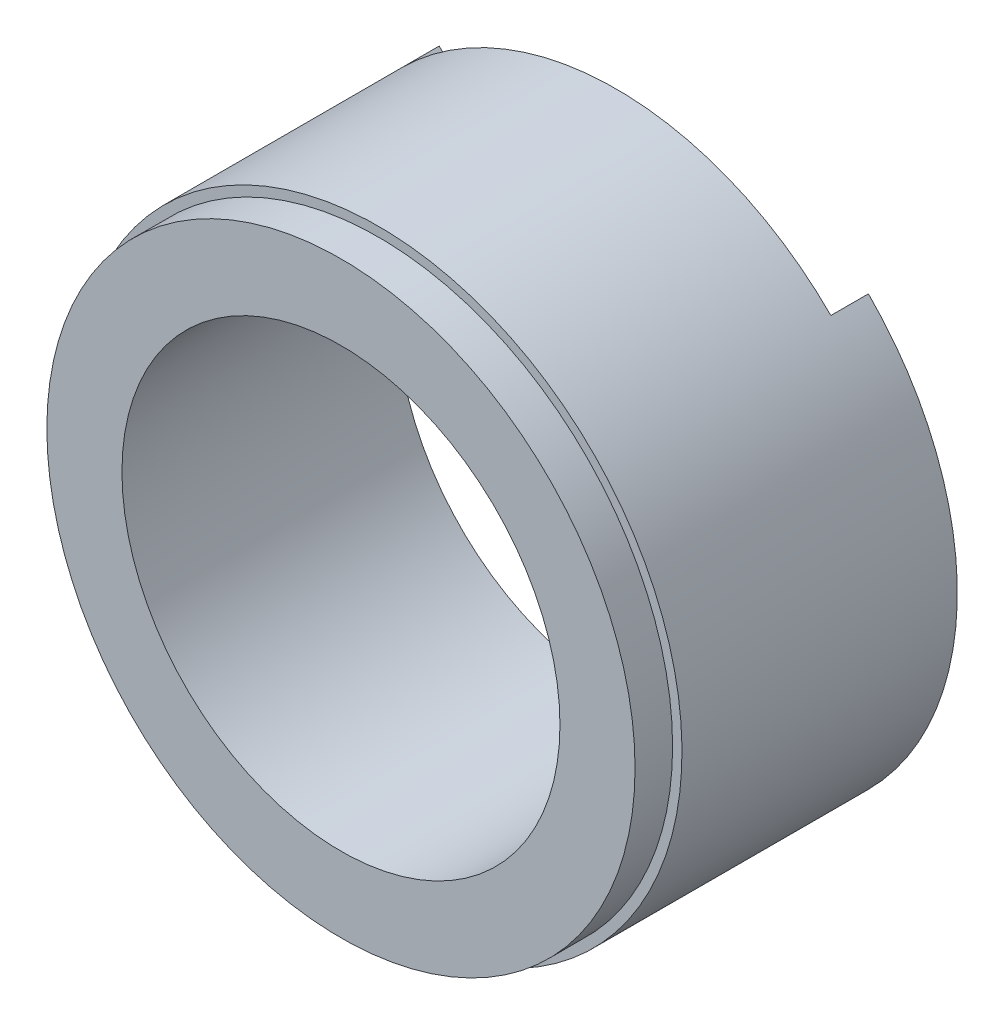
from build123d import *

# Parameters (mm, degrees)
ESQUISSE1_R             = 48.5
BOSS_EXTRU_1_DEPTH      = 44
ESQUISSE2_R             = 48.5
ESQUISSE2_R_2           = 47
ENL_V_MAT_EXTRU_1_DEPTH = 6
ESQUISSE3_R             = 35
ENL_V_MAT_EXTRU_2_DEPTH = 45
ESQUISSE5_R             = 45.5
ESQUISSE5_R_2           = 36.5
ENL_V_MAT_EXTRU_3_DEPTH = 42
ESQUISSE6_W             = 20
ESQUISSE6_H             = 4.166829754
ENL_V_MAT_EXTRU_5_DEPTH = 42
BOSS_EXTRU_2_DEPTH      = 6


with BuildPart() as part:
    # Esquisse1 → Boss.-Extru.1 (new body)
    with BuildSketch(Plane.XY):
        Circle(ESQUISSE1_R)
    extrude(amount=BOSS_EXTRU_1_DEPTH)

    # Esquisse2 → Enlèv. mat.-Extru.1 (cut)
    with BuildSketch(Plane.XY.offset(44)):
        Circle(ESQUISSE2_R)
        Circle(ESQUISSE2_R_2, mode=Mode.SUBTRACT)
    extrude(amount=-ENL_V_MAT_EXTRU_1_DEPTH, mode=Mode.SUBTRACT)

    # Esquisse3 → Enlèv. mat.-Extru.2 (cut, through all)
    with BuildSketch(Plane.XY.offset(44)):
        Circle(ESQUISSE3_R)
    extrude(amount=-ENL_V_MAT_EXTRU_2_DEPTH, mode=Mode.SUBTRACT)

    # Esquisse5 → Enlèv. mat.-Extru.3 (cut)
    with BuildSketch(Plane(origin=(0, 0, 0), x_dir=(-1, 0, 0), z_dir=(0, 0, -1))):
        Circle(ESQUISSE5_R)
        Circle(ESQUISSE5_R_2, mode=Mode.SUBTRACT)
    extrude(amount=-ENL_V_MAT_EXTRU_3_DEPTH, mode=Mode.SUBTRACT)

    # Esquisse6 → Enlèv. mat.-Extru.5 (cut)
    with BuildSketch(Plane(origin=(0, 0, 0), x_dir=(-1, 0, 0), z_dir=(0, 0, -1))):
        with Locations((0, -46.470913117)):
            Rectangle(ESQUISSE6_W, ESQUISSE6_H)
    extrude(amount=-ENL_V_MAT_EXTRU_5_DEPTH, mode=Mode.SUBTRACT)

    # Esquisse8 → Boss.-Extru.2 (add)
    with BuildSketch(Plane(origin=(0, 0, 0), x_dir=(-1, 0, 0), z_dir=(0, 0, -1))):
        with BuildLine():
            ThreePointArc((34.294678888, -34.294678888), (48.5, 0), (34.294678888, 34.294678888))
            Line((34.294678888, 34.294678888), (32.173358544, 32.173358544))
            ThreePointArc((32.173358544, 32.173358544), (45.5, 0), (32.173358544, -32.173358544))
            Line((32.173358544, -32.173358544), (34.294678888, -34.294678888))
        make_face()
        with BuildLine():
            ThreePointArc((-34.294678888, -34.294678888), (-48.5, 0), (-34.294678888, 34.294678888))
            Line((-34.294678888, 34.294678888), (-32.173358544, 32.173358544))
            ThreePointArc((-32.173358544, 32.173358544), (-45.5, 0), (-32.173358544, -32.173358544))
            Line((-32.173358544, -32.173358544), (-34.294678888, -34.294678888))
        make_face()
    extrude(amount=BOSS_EXTRU_2_DEPTH)


solid = part.part
